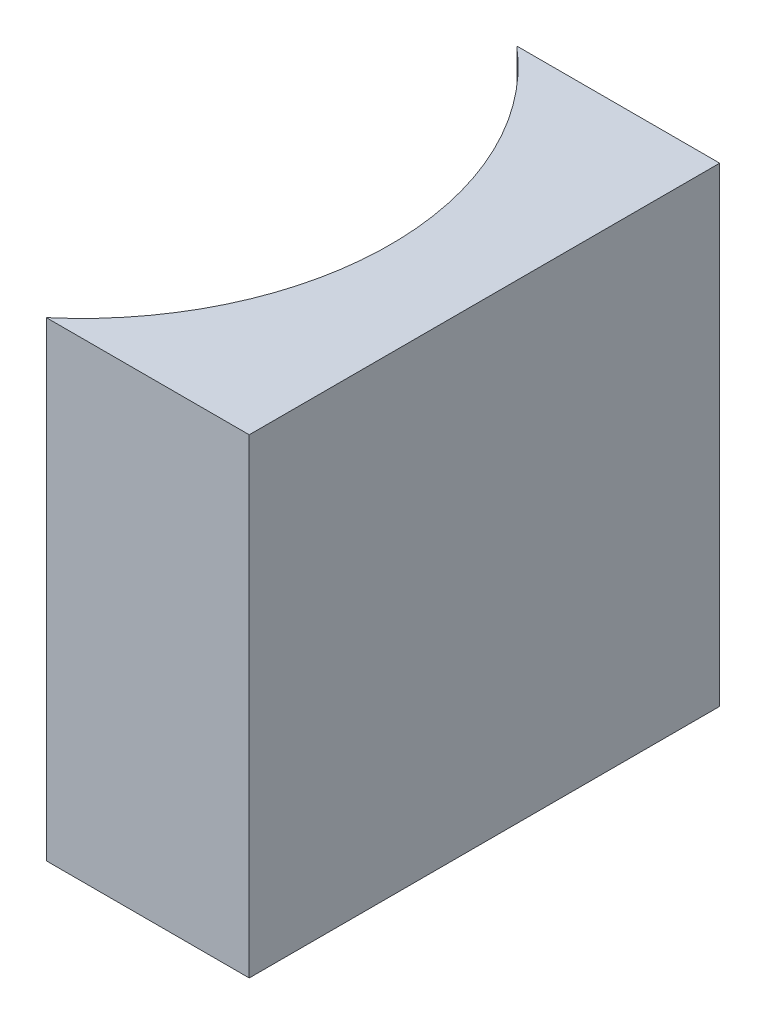
from build123d import *

# Parameters (mm, degrees)
EXTRUDE_1_DEPTH = 10


with BuildPart() as part:
    # 草图1 → 凸台-拉伸1 (new body)
    with BuildSketch(Plane(origin=(0, 0, 0), x_dir=(1, 0, 0), z_dir=(0, 1, 0))):
        with BuildLine():
            Line((0, 0), (0, -10))
            Line((0, -10), (-4.313401361, -10))
            ThreePointArc((-4.313401361, -10), (-2, -5), (-4.313401361, 0))
            Line((-4.313401361, 0), (0, 0))
        make_face()
    extrude(amount=EXTRUDE_1_DEPTH)


solid = part.part
